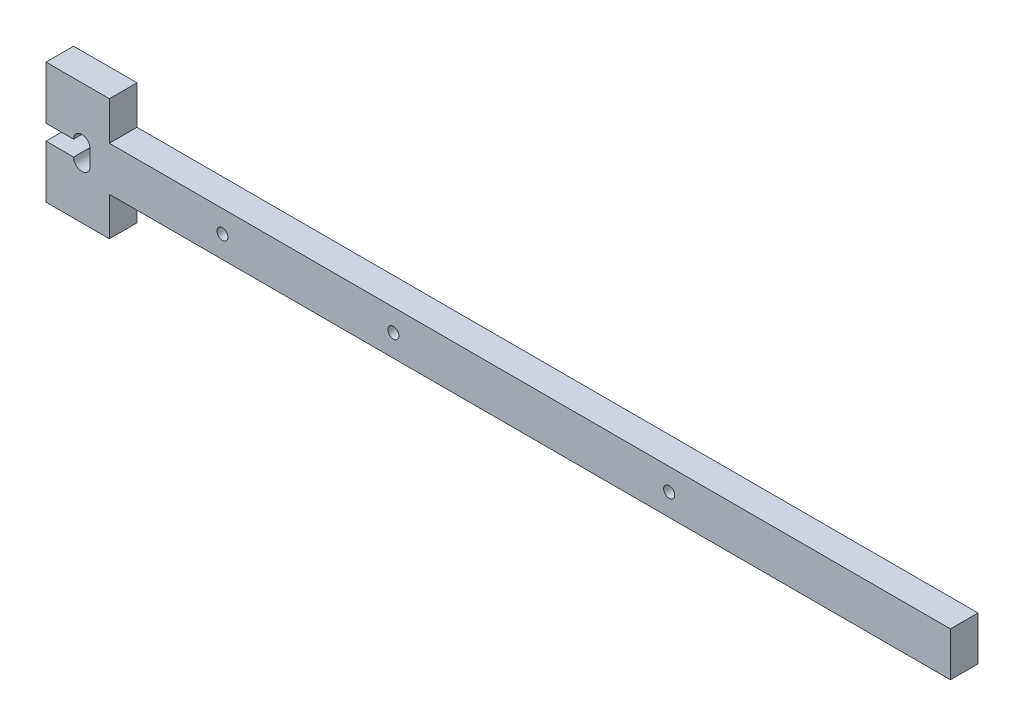
from build123d import *

# Parameters (mm, degrees)
SKETCH_3_R      = 1
EXTRUDE_3_DEPTH = 5


with BuildPart() as part:
    # 草图3 → 凸台-拉伸3 (new body)
    with BuildSketch(Plane.XY):
        with BuildLine():
            Line((2726.161531979, 4664.634627263), (2573.661531979, 4664.653356317))
            Line((2573.661531979, 4664.653356317), (2573.661531979, 4671.643884914))
            Line((2573.661531979, 4671.643884914), (2562.161531979, 4671.643884914))
            Line((2562.161531979, 4671.643884914), (2562.161531979, 4662.034400913))
            Line((2562.161531979, 4662.034400913), (2567.161531979, 4662.034400913))
            ThreePointArc((2567.161531979, 4662.034400913), (2568.661531979, 4663.534400913), (2570.161531979, 4662.034400913))
            Line((2570.161531979, 4662.034400913), (2570.161531979, 4659.234400913))
            ThreePointArc((2570.161531979, 4659.234400913), (2568.661531979, 4657.734400913), (2567.161531979, 4659.234400913))
            Line((2567.161531979, 4659.234400913), (2562.161531979, 4659.234400913))
            Line((2562.161531979, 4659.234400913), (2562.161531979, 4649.791778919))
            Line((2562.161531979, 4649.791778919), (2562.161531979, 4649.643884914))
            Line((2562.161531979, 4649.643884914), (2573.661531979, 4649.643884914))
            Line((2573.661531979, 4649.643884914), (2573.661531979, 4656.634400913))
            Line((2573.661531979, 4656.634400913), (2726.161531979, 4656.634400913))
            Line((2726.161531979, 4656.634400913), (2726.161531979, 4664.634627263))
        make_face()
        with Locations((2594.161531979, 4660.639111823)):
            Circle(SKETCH_3_R, mode=Mode.SUBTRACT)
        with Locations((2625.161531979, 4660.639111823)):
            Circle(SKETCH_3_R, mode=Mode.SUBTRACT)
        with Locations((2675.161531979, 4660.639111823)):
            Circle(SKETCH_3_R, mode=Mode.SUBTRACT)
    extrude(amount=EXTRUDE_3_DEPTH)


solid = part.part
